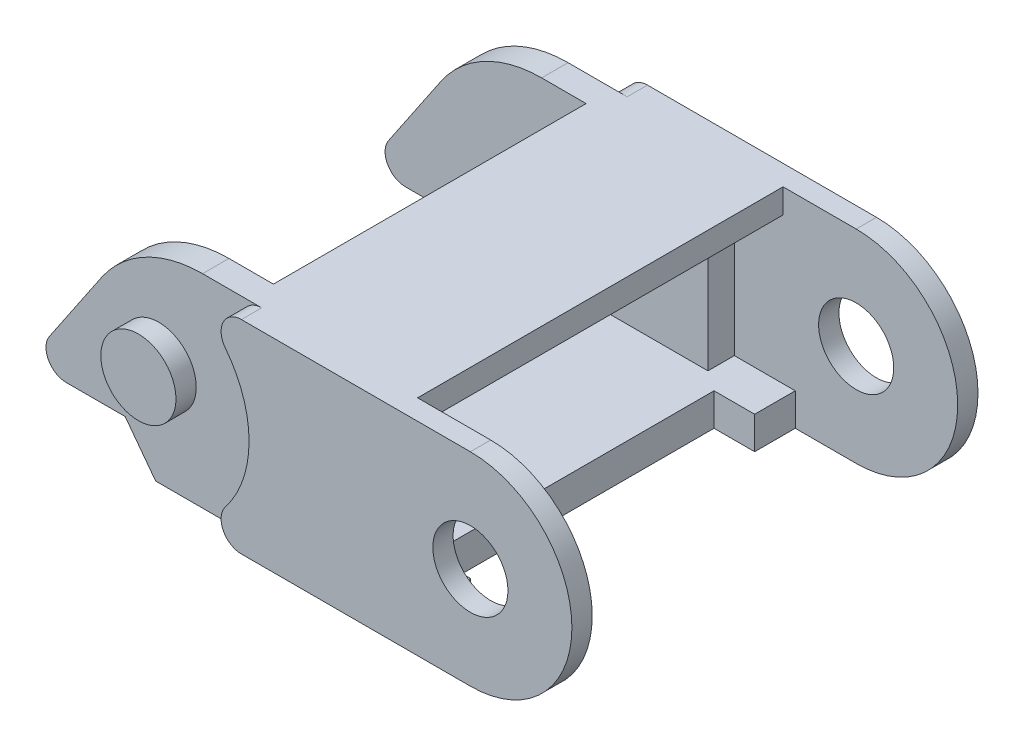
from build123d import *

# Parameters (mm, degrees)
BASE_DEPTH          = 1.6
SKETCH4_R           = 1.85
ONESIDE_DEPTH       = 1
ANOTHERSIDE_DEPTH   = 1.3
SKETCH5_3_R         = 1.85
PIN_DEPTH           = 1
BOSS_EXTRUDE9_DEPTH = 1.2


with BuildPart() as part:
    # Sketch3 → Base (new body)
    with BuildSketch(Plane(origin=(0, 0, 0), x_dir=(1, 0, 0), z_dir=(0, 1, 0))):
        Polygon((4, 7), (4, 10), (-4, 10), (-4, -10), (4, -10), (4, -7), (2, -7), (2, 7), align=None)
    extrude(amount=BASE_DEPTH)

    # Sketch4 → OneSide (add)
    with BuildSketch(Plane.XY.offset(10)):
        with BuildLine():
            ThreePointArc((-5.064751599, 1.615384615), (-5.175241651, 0.56147099), (-4.276524617, 0))
            Line((-4.276524617, 0), (-4, 0))
            Line((-4, 0), (-4, 1.6))
            Line((-4, 1.6), (4, 1.6))
            Line((4, 1.6), (4, 0))
            Line((4, 0), (7, 0))
            ThreePointArc((7, 0), (12, 5), (7, 10))
            Line((7, 10), (-4.276524617, 10))
            ThreePointArc((-4.276524617, 10), (-5.175241651, 9.43852901), (-5.064751599, 8.384615385))
            ThreePointArc((-5.064751599, 8.384615385), (-3.9, 5), (-5.064751599, 1.615384615))
        make_face()
        with Locations((7, 5)):
            Circle(SKETCH4_R, mode=Mode.SUBTRACT)
    oneside = extrude(amount=-ONESIDE_DEPTH)

    # Sketch5 → AnotherSide (add)
    with BuildSketch(Plane(origin=(0, 0, 9), x_dir=(-1, 0, 0), z_dir=(0, 0, -1))):
        with BuildLine():
            Line((-1, 10), (-1, 0))
            Line((-1, 0), (9.5, 0))
            Line((9.5, 0), (11, 2))
            Line((11, 2), (13.9, 2))
            ThreePointArc((13.9, 2), (14.783156083, 2.530920761), (14.728540367, 3.559929335))
            Line((14.728540367, 3.559929335), (12.160731096, 7.35957601))
            ThreePointArc((12.160731096, 7.35957601), (10.003964328, 9.2989365), (7.189488894, 10))
            Line((7.189488894, 10), (-1, 10))
        make_face()
    anotherside = extrude(amount=ANOTHERSIDE_DEPTH)

    # Sketch5_3 → Pin (add)
    with BuildSketch(Plane(origin=(0, 0, 9), x_dir=(-1, 0, 0), z_dir=(0, 0, -1))):
        with Locations((9.35, 5)):
            Circle(SKETCH5_3_R)
    pin = extrude(amount=-PIN_DEPTH)

    # Mirror1: OneSide, AnotherSide, Pin across plane
    add(oneside.mirror(Plane.XY))
    add(anotherside.mirror(Plane.XY))
    add(pin.mirror(Plane.XY))

    # Sketch6 → Boss-Extrude9 (add)
    with BuildSketch(Plane(origin=(0, 10, 0), x_dir=(1, 0, 0), z_dir=(0, 1, 0))):
        Polygon((-5, 8.547893693), (-5, -8.525702736), (3.4, -9.520454617), (3.4, 9.588680541), align=None)
    extrude(amount=-BOSS_EXTRUDE9_DEPTH)


solid = part.part
